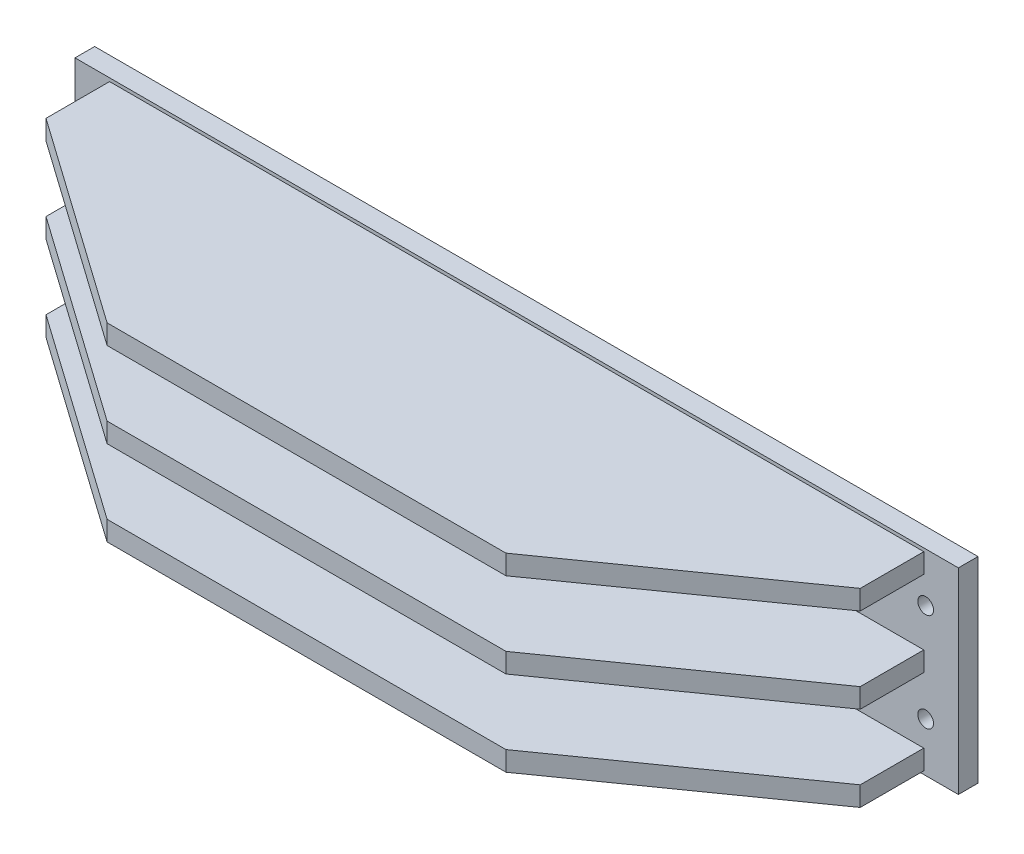
from build123d import *

# Parameters (mm, degrees)
SKETCH1_W           = 1350
SKETCH1_H           = 300
EXTRUDE1_DEPTH      = 30
SKETCH2_R           = 12
CUT_EXTRUDE1_DEPTH  = 31
EXTRUDE2_DEPTH      = 15
LPATTERN1_COUNT     = 2
LPATTERN1_PITCH     = 130
LPATTERN1_COL_COUNT = 2
LPATTERN1_COL_PITCH = 130


with BuildPart() as part:
    # Sketch1 → Extrude1 (new body)
    with BuildSketch(Plane.XY):
        with Locations((50.339261683, -50.554392858)):
            Rectangle(SKETCH1_W, SKETCH1_H)
    extrude(amount=EXTRUDE1_DEPTH)

    # Sketch2 → Cut-Extrude1 (cut, through all)
    with BuildSketch(Plane.XY.offset(30)):
        with Locations((675.339261683, 24.445607142)):
            Circle(SKETCH2_R)
        with Locations((675.339261683, -125.554392858)):
            Circle(SKETCH2_R)
        with Locations(Location((-574.660738317, -125.554392858, 0), (0, 0, 180))):  # turned: the seam where the file's is
            Circle(SKETCH2_R)
        with Locations(Location((-574.660738317, 24.445607142, 0), (0, 0, 180))):  # turned: the seam where the file's is
            Circle(SKETCH2_R)
    extrude(amount=-CUT_EXTRUDE1_DEPTH, mode=Mode.SUBTRACT)

    # Sketch3 → Extrude2 (add, symmetric)
    with BuildSketch(Plane(origin=(-624.660738317, -50.554392858, 0), x_dir=(1, 0, 0), z_dir=(0, -1, 0))):
        Polygon((52.834900275, 30), (52.834900275, 127.16727695), (370.2, 351.189991199), (979.8, 351.189991199), (1297.165099725, 127.16727695), (1297.165099725, 30), align=None)
    extrude2 = extrude(amount=EXTRUDE2_DEPTH, both=True)

    # LPattern1: Extrude2 ×2
    with Locations(*[(0, -i * LPATTERN1_PITCH, 0) for i in range(1, LPATTERN1_COUNT)]):
        add(extrude2)

    # LPattern1 col: Extrude2 ×2
    with Locations(*[(0, i * LPATTERN1_COL_PITCH, 0) for i in range(1, LPATTERN1_COL_COUNT)]):
        add(extrude2)


solid = part.part
